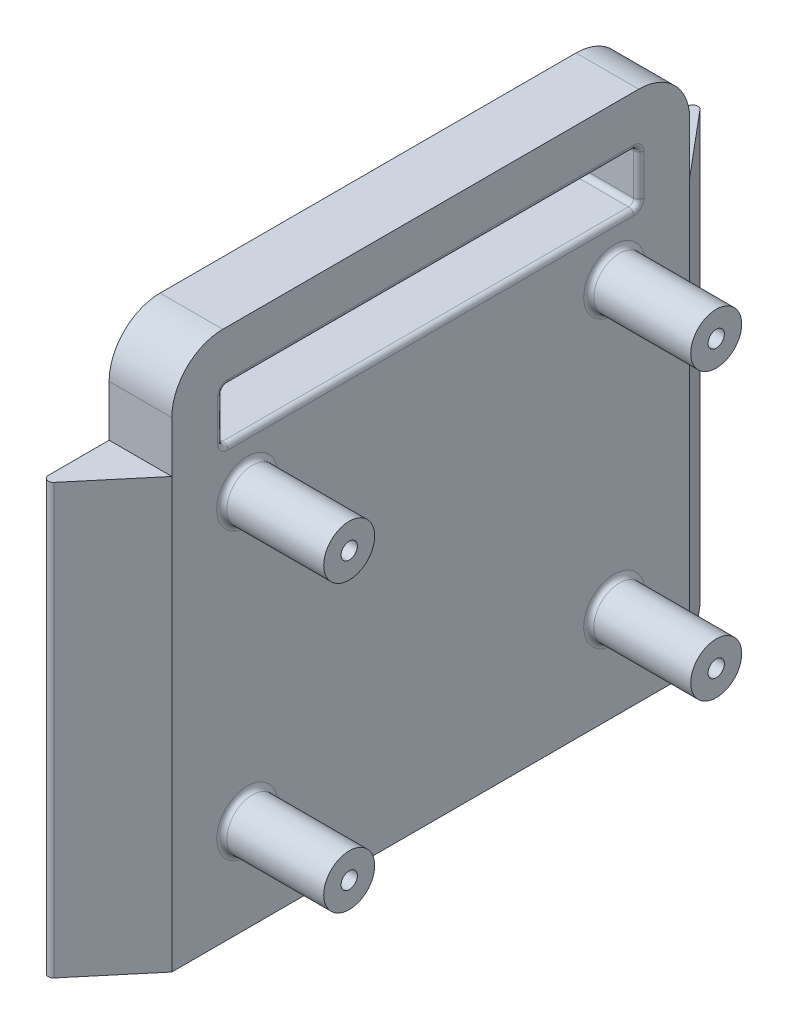
from build123d import *

# Parameters (mm, degrees)
BOSS_EXTRUDE1_DEPTH       = 114.2
SKETCH4_R                 = 5
BOSS_EXTRUDE2_DEPTH       = 20
F_5_0MM_DOWEL_HOLE1_D     = 3.2
F_5_0MM_DOWEL_HOLE1_DEPTH = 10
BOSS_EXTRUDE3_DEPTH       = 12.3
FILLET1_R                 = 10
FILLET2_R                 = 1
CUT_EXTRUDE1_DEPTH        = 30


with BuildPart() as part:
    # Sketch2 → Boss-Extrude1 (new body)
    with BuildSketch(Plane(origin=(0, 0, 0), x_dir=(1, 0, 0), z_dir=(0, 1, 0))):
        Polygon((12.3, -50.8), (12.3, 50.8), (0, 65.458569189), (0, -65.458569189), align=None)
    extrude(amount=BOSS_EXTRUDE1_DEPTH)

    # Sketch4 → Boss-Extrude2 (add)
    with BuildSketch(Plane(origin=(12.3, 0, 0), x_dir=(0, 0, -1), z_dir=(1, 0, 0))):
        with Locations((-36, 104.2)):
            Circle(SKETCH4_R)
        with Locations((36, 104.2)):
            Circle(SKETCH4_R)
        with Locations((36, 48.2)):
            Circle(SKETCH4_R)
        with Locations((-36, 48.2)):
            Circle(SKETCH4_R)
    extrude(amount=BOSS_EXTRUDE2_DEPTH)

    # Ø5.0mm Dowel Hole1
    with Locations(Plane(origin=(32.3, 0, 0), x_dir=(0, 0, -1), z_dir=(1, 0, 0))):
        with Locations((-36, 104.2), (36, 104.2), (36, 48.2), (-36, 48.2)):
            Hole(F_5_0MM_DOWEL_HOLE1_D / 2, depth=F_5_0MM_DOWEL_HOLE1_DEPTH)

    # Sketch8 → Boss-Extrude3 (add)
    with BuildSketch(Plane(origin=(0, 0, 0), x_dir=(0, 0, -1), z_dir=(1, 0, 0))):
        Polygon((-50.8, 114.2), (-40.8, 114.2), (-40.8, 124.2), (40.8, 124.2), (40.8, 114.2), (50.8, 114.2), (50.8, 134.2), (-50.8, 134.2), align=None)
    extrude(amount=BOSS_EXTRUDE3_DEPTH)

    # Fillet1
    fillet1_edges = [part.edges().sort_by_distance(p)[0] for p in [
        (6.15, 134.2, -50.8),
        (6.15, 134.2, 50.8),
    ]]
    fillet(fillet1_edges, radius=FILLET1_R)

    # Fillet2
    fillet2_edges = [part.edges().sort_by_distance(p)[0] for p in [
        (0, 57.1, 65.458569189),
        (12.3, 119.2, -40.8),
        (0, 119.2, -40.8),
        (12.3, 124.2, 0),
        (0, 124.2, 0),
        (12.3, 114.2, 0),
        (12.3, 48.2, -31),
        (12.3, 48.2, 41),
        (12.3, 104.2, 41),
        (12.3, 104.2, -31),
        (12.3, 119.2, 40.8),
        (0, 119.2, 40.8),
        (6.15, 114.2, -40.8),
        (6.15, 124.2, -40.8),
        (6.15, 124.2, 40.8),
        (6.15, 114.2, 40.8),
        (0, 57.1, -65.458569189),
        (0, 114.2, 0),
    ]]
    fillet(fillet2_edges, radius=FILLET2_R)

    # Sketch10 → Cut-Extrude1 (cut)
    with BuildSketch(Plane.XZ):
        with BuildLine():
            Line((12.3, -50.8), (1.766044443, -63.353879379))
            ThreePointArc((1.766044443, -63.353879379), (0.657979857, -63.65078439), (0, -62.711091769))
            Line((0, -62.711091769), (0, 62.711091769))
            ThreePointArc((0, 62.711091769), (0.657979857, 63.65078439), (1.766044443, 63.353879379))
            Line((1.766044443, 63.353879379), (12.3, 50.8))
            Line((12.3, 50.8), (12.3, -50.8))
        make_face()
    extrude(amount=-CUT_EXTRUDE1_DEPTH, mode=Mode.SUBTRACT)


solid = part.part
